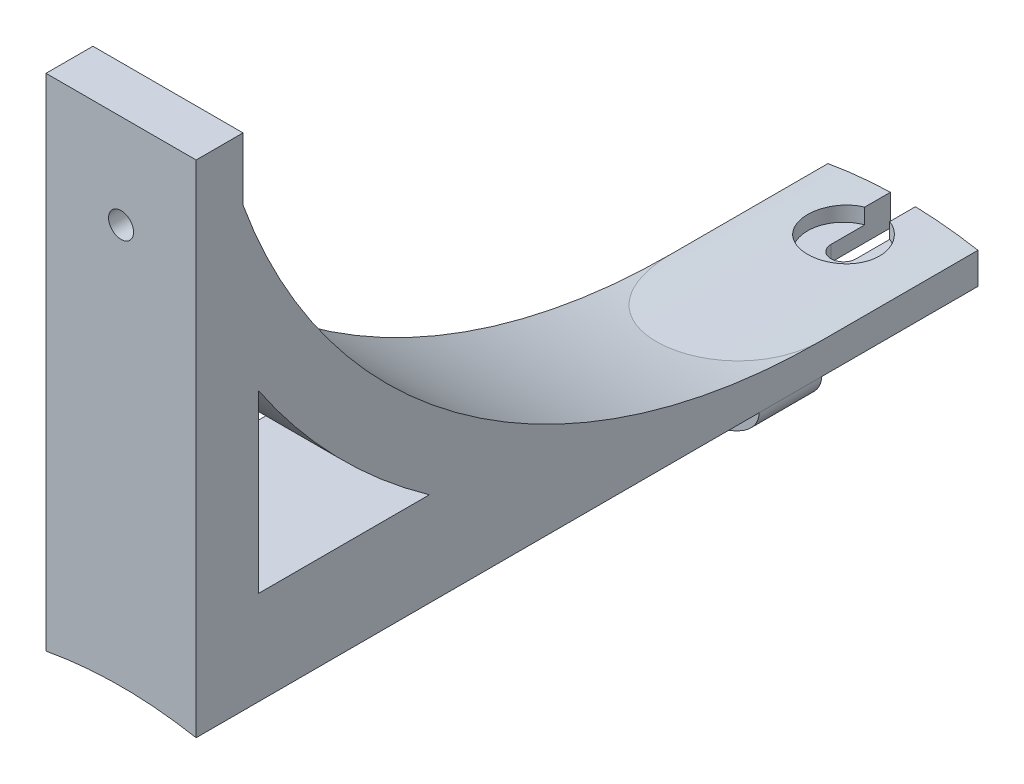
from build123d import *

# Parameters (mm, degrees)
BOSS_EXTRUDE1_DEPTH      = 100
BOSS_EXTRUDE1_DEPTH_BACK = 25
BOSS_EXTRUDE2_DEPTH      = 10
BOSS_EXTRUDE4_DEPTH      = 24
CUT_EXTRUDE3_DEPTH       = 74.936773252
CUT_EXTRUDE3_DEPTH_BACK  = 13.126453596
SKETCH9_R                = 5.75
CUT_EXTRUDE4_DEPTH       = 2.5
SKETCH10_R               = 2
CUT_EXTRUDE5_DEPTH       = 118.5000001
CUT_EXTRUDE5_DEPTH_BACK  = 8.5
SKETCH11_R               = 4.5
CUT_EXTRUDE6_DEPTH       = 118.5000001


with BuildPart() as part:
    # Sketch1 → Boss-Extrude1 (new body, two sides)
    with BuildSketch(Plane.XY) as boss_extrude1_sk:
        with BuildLine():
            Line((-12, 69.137060269), (-12, 64.137060269))
            ThreePointArc((-12, 64.137060269), (0, 65.25), (12, 64.137060269))
            Line((12, 64.137060269), (12, 69.137060269))
            ThreePointArc((12, 69.137060269), (0, 70.200287018), (-12, 69.137060269))
        make_face()
    extrude(amount=BOSS_EXTRUDE1_DEPTH)
    extrude(boss_extrude1_sk.sketch, amount=-BOSS_EXTRUDE1_DEPTH_BACK)

    # Sketch2 → Boss-Extrude2 (add)
    with BuildSketch(Plane.XY):
        with BuildLine():
            ThreePointArc((12, 64.137060269), (0, 65.25), (-12, 64.137060269))
            add(Edge.make_bspline(
                [(-12, 64.137060269), (-12, 58.073833521), (0, 58.073833521), (12, 58.073833521), (12, 64.137060269)],
                knots=[3.141592654, 3.141592654, 3.141592654, 4.71238898, 4.71238898, 6.283185307, 6.283185307, 6.283185307], degree=2, weights=[1, 0.707106781, 1, 0.707106781, 1]))
        make_face()
    extrude(amount=BOSS_EXTRUDE2_DEPTH)

    # Sketch3 → Boss-Extrude4 (add)
    with BuildSketch(Plane.ZY.offset(12)):
        with BuildLine():
            Line((92.5, 134.137060269), (92.5, 144.137060269))
            Line((92.5, 144.137060269), (100, 144.137060269))
            Line((100, 144.137060269), (100, 69.137060269))
            Line((100, 69.137060269), (0, 69.137060269))
            ThreePointArc((0, 69.137060269), (56.527095273, 87.01196315), (92.5, 134.137060269))
        make_face()
        with BuildLine():
            Line((90, 79.137060269), (90, 107.182988803))
            ThreePointArc((90, 107.182988803), (77.632594826, 91.917493745), (62.71118168, 79.137060269))
            Line((62.71118168, 79.137060269), (90, 79.137060269))
        make_face(mode=Mode.SUBTRACT)
    extrude(amount=-BOSS_EXTRUDE4_DEPTH)

    # Sketch8 → Cut-Extrude3 (cut, two sides)
    with BuildSketch(Plane(origin=(0, 70.200287018, -25), x_dir=(1, 0, 0), z_dir=(0, 1, 0))) as cut_extrude3_sk:
        with BuildLine():
            Line((2, -9.5), (2, 0))
            Line((2, 0), (-2, 0))
            Line((-2, 0), (-2, -9.5))
            ThreePointArc((-2, -9.5), (0, -11.5), (2, -9.5))
        make_face()
    extrude(amount=CUT_EXTRUDE3_DEPTH, mode=Mode.SUBTRACT)
    extrude(cut_extrude3_sk.sketch, amount=-CUT_EXTRUDE3_DEPTH_BACK, mode=Mode.SUBTRACT)

    # Sketch9 → Cut-Extrude4 (cut)
    with BuildSketch(Plane(origin=(0, 70.200287018, -25), x_dir=(1, 0, 0), z_dir=(0, 1, 0))):
        with Locations((0, -9.5)):
            Circle(SKETCH9_R)
    extrude(amount=-CUT_EXTRUDE4_DEPTH, mode=Mode.SUBTRACT)

    # Sketch10 → Cut-Extrude5 (cut, two sides)
    with BuildSketch(Plane(origin=(0, 0, 92.5), x_dir=(-1, 0, 0), z_dir=(0, 0, -1))) as cut_extrude5_sk:
        with Locations((0, 129.137060269)):
            Circle(SKETCH10_R)
    extrude(amount=CUT_EXTRUDE5_DEPTH, mode=Mode.SUBTRACT)
    extrude(cut_extrude5_sk.sketch, amount=-CUT_EXTRUDE5_DEPTH_BACK, mode=Mode.SUBTRACT)

    # Sketch11 → Cut-Extrude6 (cut, through all)
    with BuildSketch(Plane(origin=(0, 0, 92.5), x_dir=(-1, 0, 0), z_dir=(0, 0, -1))):
        with Locations((0, 129.137060269)):
            Circle(SKETCH11_R)
    extrude(amount=CUT_EXTRUDE6_DEPTH, mode=Mode.SUBTRACT)


solid = part.part
